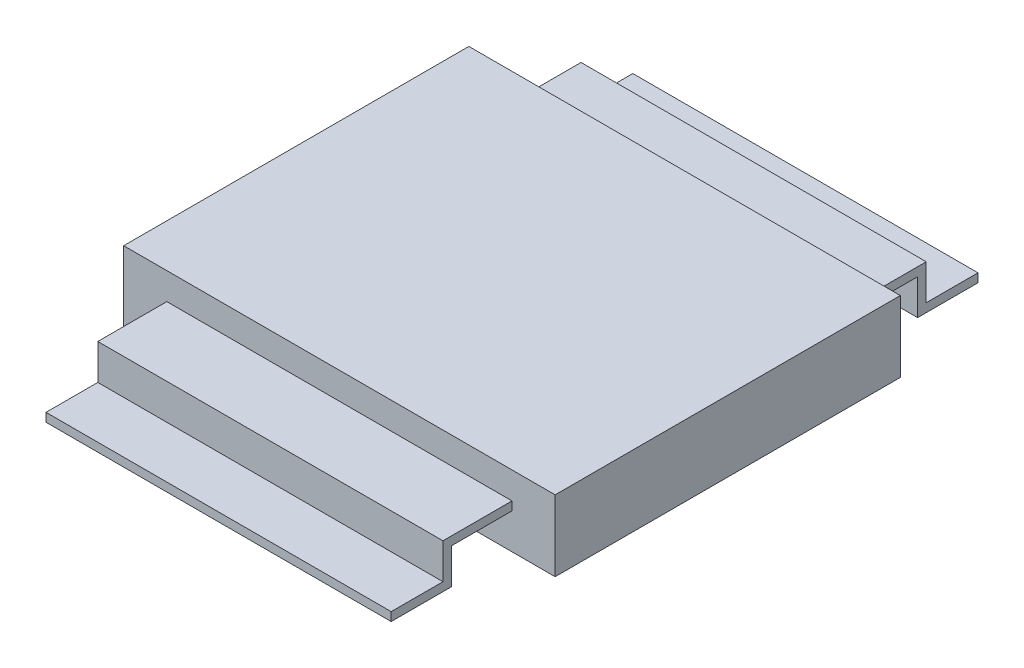
from build123d import *

# Parameters (mm, degrees)
SKETCH1_W           = 5.08
SKETCH1_H           = 1.044000004
BOSS_EXTRUDE1_DEPTH = 3.175
EXTRUDE_THIN1_DEPTH = 2.54


with BuildPart() as part:
    # Sketch1 → Boss-Extrude1 (new body, symmetric)
    with BuildSketch(Plane(origin=(0, 0, 0), x_dir=(0, 0, -1), z_dir=(1, 0, 0))):
        with Locations((0, 0.522000002)):
            Rectangle(SKETCH1_W, SKETCH1_H)
    extrude(amount=BOSS_EXTRUDE1_DEPTH, both=True)

    # Sketch2 → Extrude-Thin1 (add, symmetric)
    with BuildSketch(Plane(origin=(0, 0, 0), x_dir=(0, 0, -1), z_dir=(1, 0, 0))):
        Polygon((-2.54, 0.522000002), (-3.429, 0.522000002), (-3.429, 0), (-4.318, 0), (-4.318, 0.127), (-3.556, 0.127), (-3.556, 0.649000002), (-2.54, 0.649000002), align=None)
    extrude_thin1 = extrude(amount=EXTRUDE_THIN1_DEPTH, both=True)

    # Mirror1: Extrude-Thin1 across plane
    add(extrude_thin1.mirror(Plane.XY))


solid = part.part
